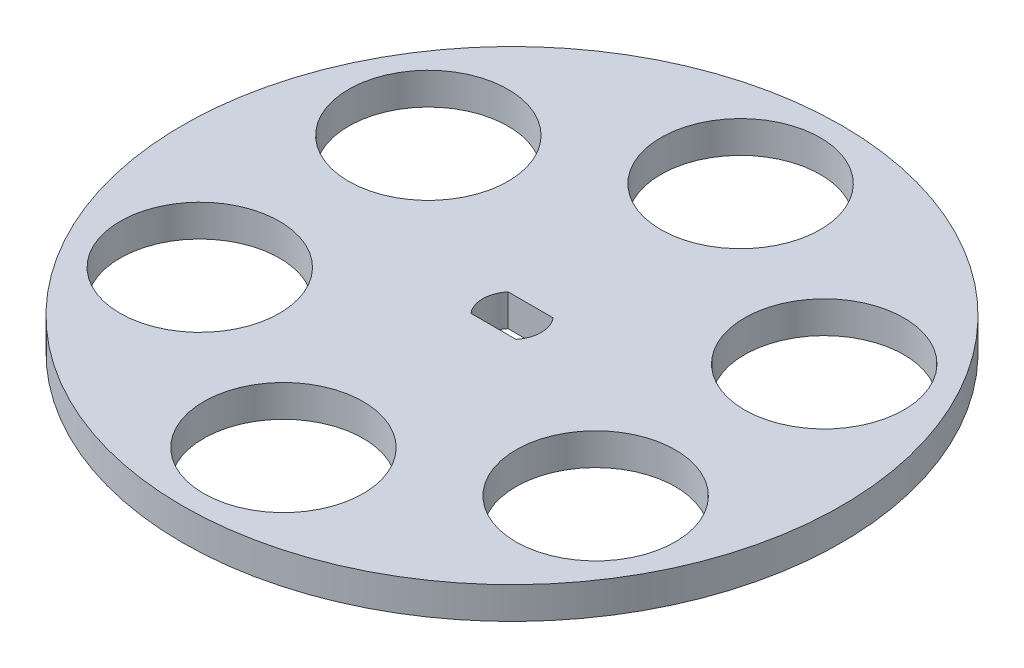
from build123d import *

# Parameters (mm, degrees)
SKETCH2_R           = 31
SKETCH2_R_2         = 7.5
BOSS_EXTRUDE1_DEPTH = 3


with BuildPart() as part:
    # Sketch2 → Boss-Extrude1 (new body)
    with BuildSketch(Plane(origin=(0, 0, 0), x_dir=(1, 0, 0), z_dir=(0, 1, 0))):
        Circle(SKETCH2_R)
        with Locations((0, 21.5)):
            Circle(SKETCH2_R_2, mode=Mode.SUBTRACT)
        with Locations((18.619546181, 10.75)):
            Circle(SKETCH2_R_2, mode=Mode.SUBTRACT)
        with Locations((18.619546181, -10.75)):
            Circle(SKETCH2_R_2, mode=Mode.SUBTRACT)
        with Locations((0, -21.5)):
            Circle(SKETCH2_R_2, mode=Mode.SUBTRACT)
        with Locations((-18.619546181, -10.75)):
            Circle(SKETCH2_R_2, mode=Mode.SUBTRACT)
        with Locations((-18.619546181, 10.75)):
            Circle(SKETCH2_R_2, mode=Mode.SUBTRACT)
        with BuildLine():
            Line((-2.121320344, 1.75), (2.121320344, 1.75))
            ThreePointArc((2.121320344, 1.75), (2.75, 0), (2.121320344, -1.75))
            Line((2.121320344, -1.75), (-2.121320344, -1.75))
            ThreePointArc((-2.121320344, -1.75), (-2.75, 0), (-2.121320344, 1.75))
        make_face(mode=Mode.SUBTRACT)
    extrude(amount=BOSS_EXTRUDE1_DEPTH)


solid = part.part
